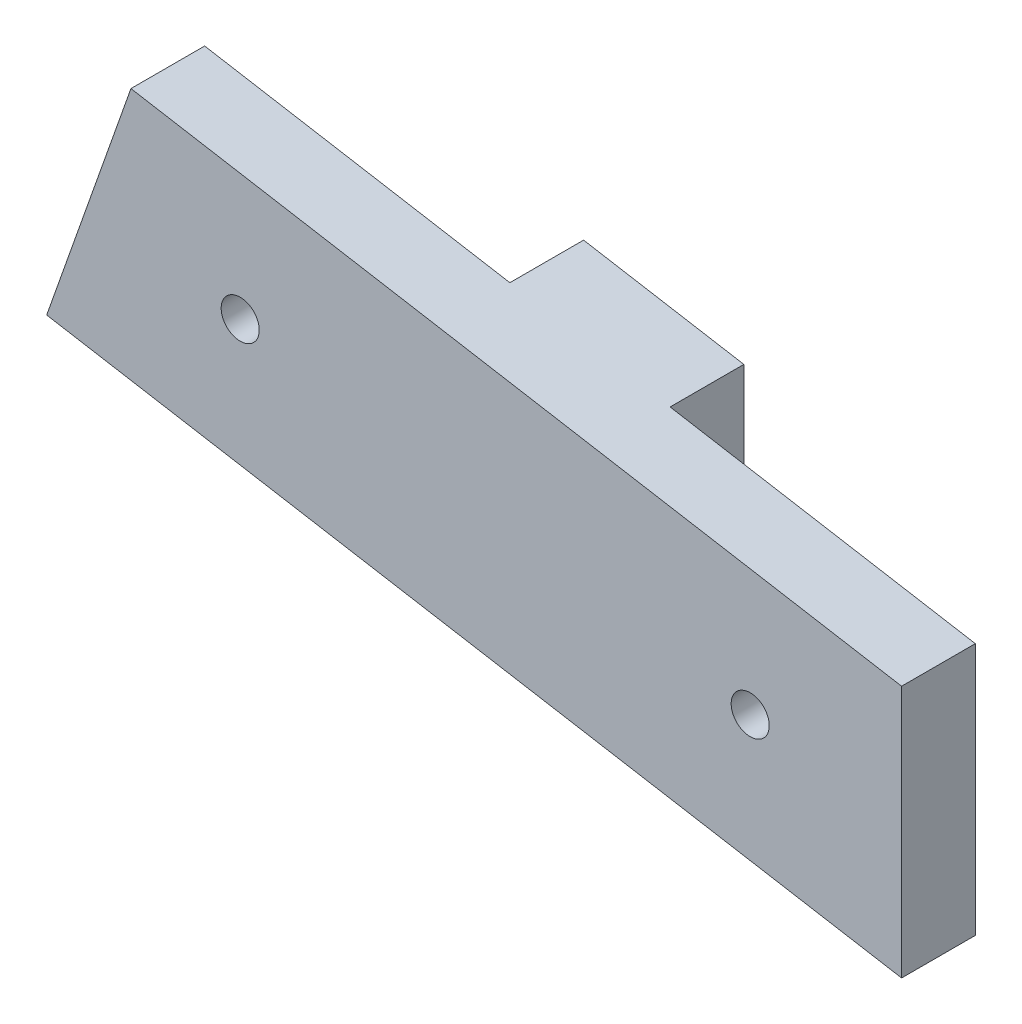
from build123d import *

# Parameters (mm, degrees)
EXTRUDE_1_DEPTH     = 6
EXTRUDE_2_DEPTH     = 6
SKETCH_3_R          = 1.55
CUT_EXTRUDE_1_DEPTH = 7


with BuildPart() as part:
    # Эскиз1 → Бобышка-Вытянуть1 (new body)
    with BuildSketch(Plane.XY):
        Polygon((-114.323496858, 125.813994573), (-183.895105895, 137.75282099), (-177.039061357, 157.140809371), (-114.323496858, 146.378513535), align=None)
    extrude(amount=EXTRUDE_1_DEPTH)

    # Эскиз2 → Бобышка-Вытянуть2 (add)
    with BuildSketch(Plane(origin=(0, 0, 0), x_dir=(-1, 0, 0), z_dir=(0, 0, -1))):
        Polygon((139.160448137, 150.64065515), (139.160448137, 130.076136187), (159.058154615, 133.490679376), (152.202110077, 152.878667757), align=None)
    extrude(amount=EXTRUDE_2_DEPTH)

    # Эскиз3 → Вырез-Вытянуть1 (cut, through all)
    with BuildSketch(Plane(origin=(0, 0, 0), x_dir=(-1, 0, 0), z_dir=(0, 0, -1))):
        with Locations((126.643413167, 138.210411601)):
            Circle(SKETCH_3_R)
        with Locations((168.147167316, 145.332657634)):
            Circle(SKETCH_3_R)
    extrude(amount=-CUT_EXTRUDE_1_DEPTH, mode=Mode.SUBTRACT)


solid = part.part
